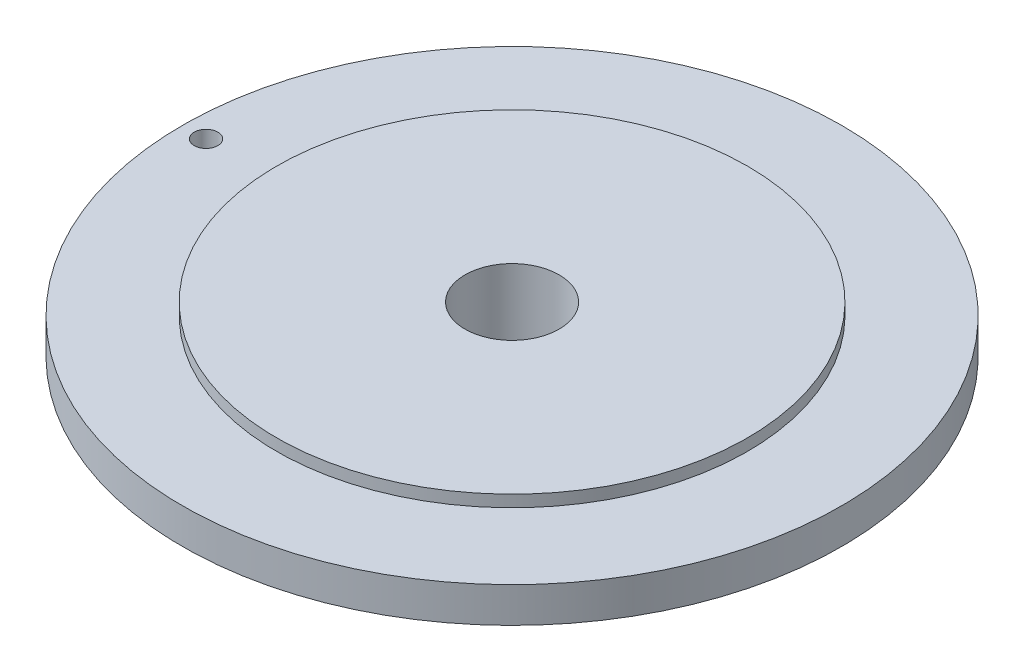
from build123d import *

# Parameters (mm, degrees)
F_1_8_0_125_DIAMETER_HOLE1_D = 3.175


with BuildPart() as part:
    # Sketch1 → Revolve1 (revolve)
    with BuildSketch(Plane.XY):
        Polygon((-6.35, 0), (-6.35, 19.05), (-31.75, 19.05), (-31.75, 17.4625), (-44.45, 17.4625), (-44.45, 12.7), (-12.7, 12.7), (-12.7, 0), (-10.9855, 0), (-10.9855, 2.032), (-7.9375, 2.032), (-7.9375, 0), align=None)
    revolve(axis=Axis((0, 0, 0), (0, 1, 0)))

    # 1/8 (0.125) Diameter Hole1 (through all)
    with Locations(Plane(origin=(0, 17.4625, 0), x_dir=(1, 0, 0), z_dir=(0, 1, 0))):
        with Locations((-41.275, 0)):
            Hole(F_1_8_0_125_DIAMETER_HOLE1_D / 2)


solid = part.part
